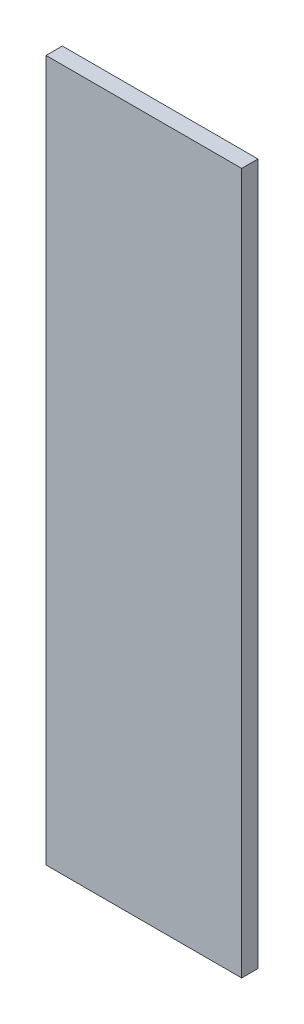
from build123d import *

# Parameters (mm, degrees)
SKETCH1_W           = 152.4
SKETCH1_H           = 546.1
BOSS_EXTRUDE1_DEPTH = 12.7


with BuildPart() as part:
    # Sketch1 → Boss-Extrude1 (new body)
    with BuildSketch(Plane.XY):
        with Locations((76.2, -50.8)):
            Rectangle(SKETCH1_W, SKETCH1_H)
    extrude(amount=BOSS_EXTRUDE1_DEPTH)


solid = part.part
